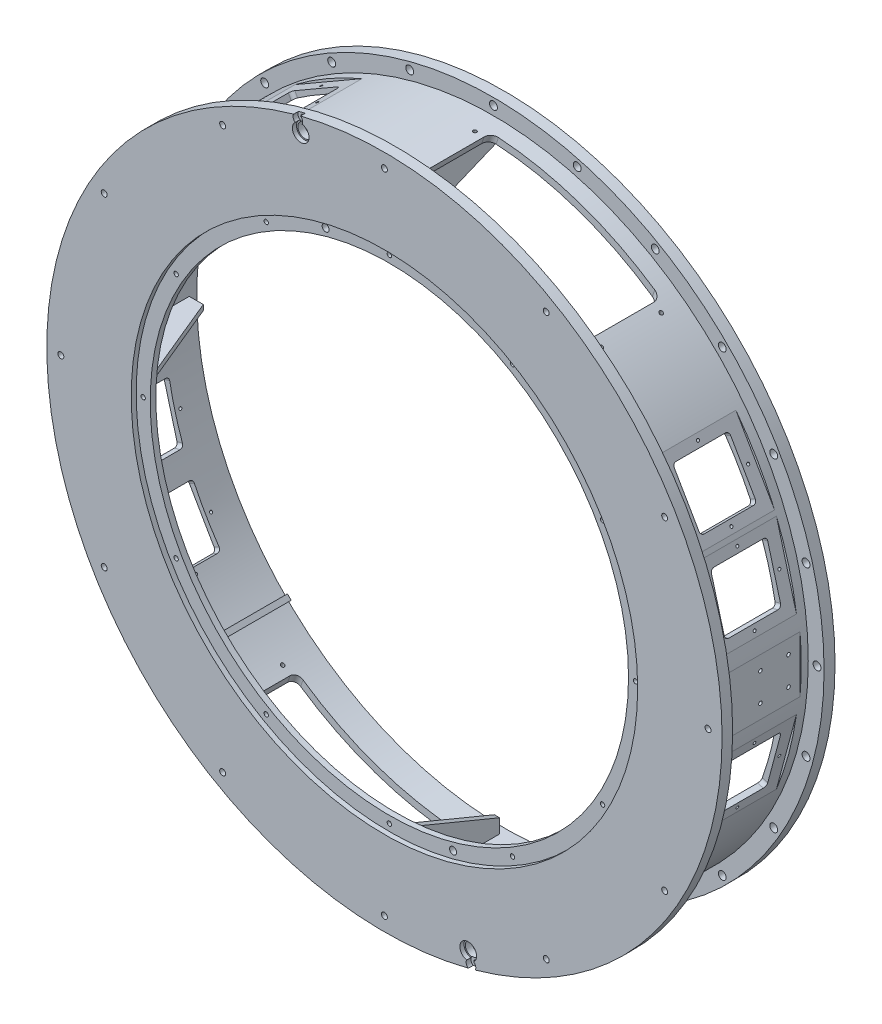
from build123d import *

# Parameters (mm, degrees)
F_1_2_13_TAPPED_HOLE1_REACH        = 218.662
F_1_2_13_TAPPED_HOLE1_BORE_R       = 5.35813
CIRPATTERN1_COUNT                  = 12
F_3_8_16_TAPPED_HOLE1_D            = 7.9375
CIRPATTERN2_COUNT                  = 12
F_9_16_0_5625_DIAMETER_HOLE1_D     = 14.2875
F_9_16_0_5625_DIAMETER_HOLE1_DEPTH = 19.813
CIRPATTERN3_COUNT                  = 24
HOLE1_D                            = 25.4
HOLE1_DEPTH                        = 19.051
HOLE1_CBORE_D                      = 30.1752
HOLE1_CBORE_DEPTH                  = 7.5184
F_5_16_18_TAPPED_HOLE1_D           = 6.5278
HOLE2_D                            = 17.4752
HOLE2_DEPTH                        = 8.6868
CIRPATTERN4_COUNT                  = 2
F_1_2_0_5_DIAMETER_HOLE1_D         = 12.7
CIRPATTERN5_COUNT                  = 2
EXTRUDE1_DEPTH                     = 4.7625
CIRPATTERN6_COUNT                  = 2
CIRPATTERN7_COUNT                  = 3
CIRPATTERN7_ANGLE                  = 90
CIRPATTERN7_COPY_1_DEPTH           = 4.7625
CIRPATTERN7_COPY_2_DEPTH           = 4.7625
EXTRUDE6_DEPTH                     = 4.7625
CIRPATTERN8_COUNT                  = 2
CUT_EXTRUDE1_DEPTH                 = 50.8
SKETCH23_R                         = 3.175
CUT_EXTRUDE3_DEPTH                 = 43.18
SKETCH27_W                         = 152.4
SKETCH27_H                         = 127
CUT_EXTRUDE4_DEPTH                 = 30.48
F_5_16_18_TAPPED_HOLE2_AT_2_COUNT  = 2
F_5_16_18_TAPPED_HOLE2_AT_2_PITCH  = 50.8
F_5_16_18_TAPPED_HOLE2_AT_3_COUNT  = 2
F_5_16_18_TAPPED_HOLE2_AT_3_PITCH  = 71.842048969
F_5_16_18_TAPPED_HOLE2_AT_4_COUNT  = 2
F_5_16_18_TAPPED_HOLE2_AT_4_PITCH  = 50.8
CIRPATTERN9_COUNT                  = 2
CIRPATTERN10_COUNT                 = 2
SKETCH31_W                         = 146.05
SKETCH31_H                         = 152.4
CUT_EXTRUDE6_DEPTH                 = 7.62
CUT_EXTRUDE7_DEPTH                 = 12.7
F_1_4_20_TAPPED_HOLE2_AT_2_COUNT   = 2
F_1_4_20_TAPPED_HOLE2_AT_2_PITCH   = 85.31243315
F_1_4_20_TAPPED_HOLE2_AT_3_COUNT   = 2
F_1_4_20_TAPPED_HOLE2_AT_3_PITCH   = 120.65
F_1_4_20_TAPPED_HOLE2_AT_4_COUNT   = 2
F_1_4_20_TAPPED_HOLE2_AT_4_PITCH   = 85.31243315
CIRPATTERN11_COUNT                 = 4
CIRPATTERN12_COUNT                 = 2
CIRPATTERN12_ANGLE                 = 15
CIRPATTERN13_COUNT                 = 2
CIRPATTERN13_ANGLE                 = 45
CIRPATTERN14_COUNT                 = 2
CIRPATTERN14_ANGLE                 = 165
CIRPATTERN15_COUNT                 = 2
CIRPATTERN15_ANGLE                 = 135


with BuildPart() as part:
    # Sketch1 → Revolve1 (revolve)
    with BuildSketch(Plane(origin=(0, 0, 0), x_dir=(0, 0, -1), z_dir=(1, 0, 0)), mode=Mode.PRIVATE) as revolve1_sk:
        Polygon((0, 609.6), (19.05, 609.6), (19.05, 568.325), (196.85, 568.325), (196.85, 596.9), (216.662, 596.9), (216.662, 555.625), (19.05, 555.625), (19.05, 431.8), (8.89, 431.8), (8.89, 457.2), (0, 457.2), align=None)
    revolve(revolve1_sk.sketch.rotate(Axis((0, 0, 0), (0, 0, -1)), 90), axis=Axis((0, 0, 0), (0, 0, -1)))  # turned: the seam where the file's is

    # 1_2-13 Tapped Hole1 bore (on position points) → 1_2-13 Tapped Hole1 (cut, up to next)
    with BuildSketch(Plane(origin=(0, 584.2, 0), x_dir=(1, 0, 0), z_dir=(0, 0, 1)), mode=Mode.PRIVATE) as f_1_2_13_tapped_hole1_sk1:
        Circle(F_1_2_13_TAPPED_HOLE1_BORE_R)
    f_1_2_13_tapped_hole1_tool1 = extrude(f_1_2_13_tapped_hole1_sk1.sketch, amount=-F_1_2_13_TAPPED_HOLE1_REACH, mode=Mode.PRIVATE) & part.part
    f_1_2_13_tapped_hole1 = f_1_2_13_tapped_hole1_tool1.solids().sort_by_distance((0, 584.2, 0))[0]
    add(f_1_2_13_tapped_hole1, mode=Mode.SUBTRACT)

    # CirPattern1: 1_2-13 Tapped Hole1 ×12 about axis
    cirpattern1_axis = Axis((0, 0, 0), (0, 0, 1))
    for i in range(1, CIRPATTERN1_COUNT):
        add(f_1_2_13_tapped_hole1.rotate(cirpattern1_axis, i * 360 / CIRPATTERN1_COUNT), mode=Mode.SUBTRACT)

    # 3_8-16 Tapped Hole1 (through all)
    with Locations(Plane(origin=(0, 444.5, -8.89), x_dir=(1, 0, 0), z_dir=(0, 0, 1))):
        with Locations((0, 0)):
            f_3_8_16_tapped_hole1 = Hole(F_3_8_16_TAPPED_HOLE1_D / 2)

    # CirPattern2: 3_8-16 Tapped Hole1 ×12 about axis
    cirpattern2_axis = Axis((0, 0, 0), (0, 0, 1))
    for i in range(1, CIRPATTERN2_COUNT):
        add(f_3_8_16_tapped_hole1.rotate(cirpattern2_axis, i * 360 / CIRPATTERN2_COUNT), mode=Mode.SUBTRACT)

    # 9_16 _0.5625_ Diameter Hole1
    with Locations(Plane(origin=(0, 584.2, -216.662), x_dir=(-1, 0, 0), z_dir=(0, 0, -1))):
        with Locations((0, 0)):
            f_9_16_0_5625_diameter_hole1 = Hole(F_9_16_0_5625_DIAMETER_HOLE1_D / 2, depth=F_9_16_0_5625_DIAMETER_HOLE1_DEPTH)

    # CirPattern3: 9_16 _0.5625_ Diameter Hole1 ×24 about axis
    cirpattern3_axis = Axis((0, 0, 0), (0, 0, 1))
    for i in range(1, CIRPATTERN3_COUNT):
        add(f_9_16_0_5625_diameter_hole1.rotate(cirpattern3_axis, i * 360 / CIRPATTERN3_COUNT), mode=Mode.SUBTRACT)

    # Hole1
    with Locations(Plane(origin=(-151.202086149, 564.293867718, 0), x_dir=(1, 0, 0), z_dir=(0, 0, 1))):
        with Locations((0, 0)):
            hole1 = CounterBoreHole(HOLE1_D / 2, HOLE1_CBORE_D / 2, HOLE1_CBORE_DEPTH, depth=HOLE1_DEPTH)

    # 5_16-18 Tapped Hole1 (through all)
    with Locations(Plane(origin=(-156.237773018, 583.087306965, 0), x_dir=(1, 0, 0), z_dir=(0, 0, 1))):
        with Locations((0, 0)):
            f_5_16_18_tapped_hole1 = Hole(F_5_16_18_TAPPED_HOLE1_D / 2)

    # Hole2
    with Locations(Plane(origin=(-156.237773018, 583.087306965, 0), x_dir=(1, 0, 0), z_dir=(0, 0, 1))):
        with Locations((0, 0)):
            hole2 = Hole(HOLE2_D / 2, depth=HOLE2_DEPTH)

    # CirPattern4: Hole1, 5_16-18 Tapped Hole1, Hole2 ×2 about axis
    cirpattern4_axis = Axis((0, 0, 0), (0, 0, 1))
    add([hole1.rotate(cirpattern4_axis, i * 360 / CIRPATTERN4_COUNT) for i in range(1, CIRPATTERN4_COUNT)], mode=Mode.SUBTRACT)
    add([f_5_16_18_tapped_hole1.rotate(cirpattern4_axis, i * 360 / CIRPATTERN4_COUNT) for i in range(1, CIRPATTERN4_COUNT)], mode=Mode.SUBTRACT)
    add([hole2.rotate(cirpattern4_axis, i * 360 / CIRPATTERN4_COUNT) for i in range(1, CIRPATTERN4_COUNT)], mode=Mode.SUBTRACT)

    # 1_2 _0.5_ Diameter Hole1 (through all)
    with Locations(Plane(origin=(-115.045065548, 429.354029785, -8.89), x_dir=(1, 0, 0), z_dir=(0, 0, 1))):
        with Locations((0, 0)):
            f_1_2_0_5_diameter_hole1 = Hole(F_1_2_0_5_DIAMETER_HOLE1_D / 2)

    # CirPattern5: 1_2 _0.5_ Diameter Hole1 ×2 about axis
    cirpattern5_axis = Axis((0, 0, 0), (0, 0, 1))
    for i in range(1, CIRPATTERN5_COUNT):
        add(f_1_2_0_5_diameter_hole1.rotate(cirpattern5_axis, i * 360 / CIRPATTERN5_COUNT), mode=Mode.SUBTRACT)

    # Sketch17 → Extrude1 (add, symmetric)
    with BuildSketch(Plane(origin=(0, 0, 0), x_dir=(0, 0, -1), z_dir=(1, 0, 0))):
        Polygon((203.2, 555.625), (203.2, 530.225), (19.05, 454.025), (19.05, 546.644743879), (28.030256121, 555.625), align=None)
    extrude1 = extrude(amount=EXTRUDE1_DEPTH, both=True)

    # CirPattern6: Extrude1 ×2 about axis
    cirpattern6_axis = Axis((0, 0, 0), (0, 0, 1))
    for i in range(1, CIRPATTERN6_COUNT):
        add(extrude1.rotate(cirpattern6_axis, i * 360 / CIRPATTERN6_COUNT))

    # CirPattern7: Extrude1 ×3 about axis
    cirpattern7_axis = Axis((0, 0, 0), (0, 0, 1))
    for i in range(1, CIRPATTERN7_COUNT):
        add(extrude1.rotate(cirpattern7_axis, i * CIRPATTERN7_ANGLE / (CIRPATTERN7_COUNT - 1)))

    # CirPattern7 copy 1 sketch → CirPattern7 copy 1 (add, symmetric)
    with BuildSketch(Plane(origin=(0, 0, 0), x_dir=(0, 0, -1), z_dir=(-0.707106781, -0.707106781, 0))):
        Polygon((203.2, 555.625), (203.2, 530.225), (19.05, 454.025), (19.05, 546.644743879), (28.030256121, 555.625), align=None)
    extrude(amount=CIRPATTERN7_COPY_1_DEPTH, both=True)

    # CirPattern7 copy 2 sketch → CirPattern7 copy 2 (add, symmetric)
    with BuildSketch(Plane(origin=(0, 0, 0), x_dir=(0, 0, -1), z_dir=(0, -1, 0))):
        Polygon((203.2, 555.625), (203.2, 530.225), (19.05, 454.025), (19.05, 546.644743879), (28.030256121, 555.625), align=None)
    extrude(amount=CIRPATTERN7_COPY_2_DEPTH, both=True)

    # Sketch20 → Extrude6 (add, symmetric)
    with BuildSketch(Plane(origin=(0, 0, 0), x_dir=(0.707106781, 0.707106781, 0), z_dir=(0.707106781, -0.707106781, 0))):
        Polygon((504.825, -19.05), (546.644743879, -19.05), (555.625, -28.030256121), (555.625, -203.2), (530.225, -203.2), align=None)
    extrude6 = extrude(amount=EXTRUDE6_DEPTH, both=True)

    # CirPattern8: Extrude6 ×2 about axis
    cirpattern8_axis = Axis((0, 0, 0), (0, 0, 1))
    for i in range(1, CIRPATTERN8_COUNT):
        add(extrude6.rotate(cirpattern8_axis, i * 360 / CIRPATTERN8_COUNT))

    # Sketch22 → Cut-Extrude1 (cut)
    with BuildSketch(Plane(origin=(185.028521382, 537.361844477, 0), x_dir=(0.945518576, -0.325568154, 0), z_dir=(-0.325568154, -0.945518576, 0))):
        with BuildLine():
            ThreePointArc((-161.925, -41.402), (-158.205256121, -32.421743879), (-149.225, -28.702))
            Line((-149.225, -28.702), (149.225, -28.702))
            ThreePointArc((149.225, -28.702), (158.205256121, -32.421743879), (161.925, -41.402))
            Line((161.925, -41.402), (161.925, -155.702))
            ThreePointArc((161.925, -155.702), (158.205256121, -164.682256121), (149.225, -168.402))
            Line((149.225, -168.402), (-149.225, -168.402))
            ThreePointArc((-149.225, -168.402), (-158.205256121, -164.682256121), (-161.925, -155.702))
            Line((-161.925, -155.702), (-161.925, -41.402))
        make_face()
    cut_extrude1 = extrude(amount=CUT_EXTRUDE1_DEPTH, mode=Mode.SUBTRACT)

    # Sketch23 → Cut-Extrude3 (cut)
    with BuildSketch(Plane(origin=(185.028521382, 537.361844477, 0), x_dir=(0.945518576, -0.325568154, 0), z_dir=(-0.325568154, -0.945518576, 0))):
        with Locations(Location((-177.8, -47.752, 0), (0, 0, 180))):  # turned: the seam where the file's is
            Circle(SKETCH23_R)
        with Locations(Location((-177.8, -155.702, 0), (0, 0, 180))):  # turned: the seam where the file's is
            Circle(SKETCH23_R)
        with Locations(Location((177.8, -47.752, 0), (0, 0, 180))):  # turned: the seam where the file's is
            Circle(SKETCH23_R)
        with Locations(Location((177.8, -155.702, 0), (0, 0, 180))):  # turned: the seam where the file's is
            Circle(SKETCH23_R)
    cut_extrude3 = extrude(amount=CUT_EXTRUDE3_DEPTH, mode=Mode.SUBTRACT)

    # Sketch27 → Cut-Extrude4 (cut)
    with BuildSketch(Plane(origin=(566.050055759, 0, 0), x_dir=(0, 0, -1), z_dir=(1, 0, 0))):
        with Locations((107.95, 0)):
            Rectangle(SKETCH27_W, SKETCH27_H)
    cut_extrude4 = extrude(amount=CUT_EXTRUDE4_DEPTH, mode=Mode.SUBTRACT)

    # Sketch29 → 5_16-18 Tapped Hole2 (revolve, cut)
    with BuildSketch(Plane(origin=(566.050055759, 25.4, -112.7125), x_dir=(0, 0, -1), z_dir=(0, 1, 0))):
        Polygon((0, 0), (0, 32.695148974), (3.2639, 30.734), (3.2639, 0), align=None)
    f_5_16_18_tapped_hole2 = revolve(axis=Axis((572.400055759, 25.4, -112.7125), (-1, 0, 0)), mode=Mode.SUBTRACT)

    # 5_16-18 Tapped Hole2 at 2: 5_16-18 Tapped Hole2 ×2
    with Locations(*[(0, 0, -i * F_5_16_18_TAPPED_HOLE2_AT_2_PITCH) for i in range(1, F_5_16_18_TAPPED_HOLE2_AT_2_COUNT)]):
        add(f_5_16_18_tapped_hole2, mode=Mode.SUBTRACT)

    # 5_16-18 Tapped Hole2 at 3: 5_16-18 Tapped Hole2 ×2
    with Locations(*[Vector(0, -0.707106781, -0.707106781) * (i * F_5_16_18_TAPPED_HOLE2_AT_3_PITCH) for i in range(1, F_5_16_18_TAPPED_HOLE2_AT_3_COUNT)]):
        add(f_5_16_18_tapped_hole2, mode=Mode.SUBTRACT)

    # 5_16-18 Tapped Hole2 at 4: 5_16-18 Tapped Hole2 ×2
    with Locations(*[(0, -i * F_5_16_18_TAPPED_HOLE2_AT_4_PITCH, 0) for i in range(1, F_5_16_18_TAPPED_HOLE2_AT_4_COUNT)]):
        add(f_5_16_18_tapped_hole2, mode=Mode.SUBTRACT)

    # CirPattern9: 5_16-18 Tapped Hole2, Cut-Extrude4 ×2 about axis
    cirpattern9_axis = Axis((0, 0, 0), (0, 0, -1))
    add([f_5_16_18_tapped_hole2.rotate(cirpattern9_axis, i * 360 / CIRPATTERN9_COUNT) for i in range(1, CIRPATTERN9_COUNT)], mode=Mode.SUBTRACT)
    add([cut_extrude4.rotate(cirpattern9_axis, i * 360 / CIRPATTERN9_COUNT) for i in range(1, CIRPATTERN9_COUNT)], mode=Mode.SUBTRACT)

    # CirPattern9 copy 1 sketch → CirPattern9 copy 1 (revolve, cut)
    with BuildSketch(Plane(origin=(-566.050055759, -25.4, -163.5125), x_dir=(0, 0, -1), z_dir=(0, -1, 0))):
        Polygon((0, 0), (0, 32.695148974), (3.2639, 30.734), (3.2639, 0), align=None)
    revolve(axis=Axis((-572.400055759, -25.4, -163.5125), (1, 0, 0)), mode=Mode.SUBTRACT)

    # CirPattern9 copy 2 sketch → CirPattern9 copy 2 (revolve, cut)
    with BuildSketch(Plane(origin=(-566.050055759, 25.4, -163.5125), x_dir=(0, 0, -1), z_dir=(0, -1, 0))):
        Polygon((0, 0), (0, 32.695148974), (3.2639, 30.734), (3.2639, 0), align=None)
    revolve(axis=Axis((-572.400055759, 25.4, -163.5125), (1, 0, 0)), mode=Mode.SUBTRACT)

    # CirPattern9 copy 3 sketch → CirPattern9 copy 3 (revolve, cut)
    with BuildSketch(Plane(origin=(-566.050055759, 25.4, -112.7125), x_dir=(0, 0, -1), z_dir=(0, -1, 0))):
        Polygon((0, 0), (0, 32.695148974), (3.2639, 30.734), (3.2639, 0), align=None)
    revolve(axis=Axis((-572.400055759, 25.4, -112.7125), (1, 0, 0)), mode=Mode.SUBTRACT)

    # CirPattern10: Cut-Extrude1, Cut-Extrude3 ×2 about axis
    cirpattern10_axis = Axis((0, 0, 0), (0, 0, 1))
    add([cut_extrude1.rotate(cirpattern10_axis, i * 360 / CIRPATTERN10_COUNT) for i in range(1, CIRPATTERN10_COUNT)], mode=Mode.SUBTRACT)
    add([cut_extrude3.rotate(cirpattern10_axis, i * 360 / CIRPATTERN10_COUNT) for i in range(1, CIRPATTERN10_COUNT)], mode=Mode.SUBTRACT)

    # Sketch31 → Cut-Extrude6 (cut)
    with BuildSketch(Plane(origin=(488.452364457, 282.008104106, 0), x_dir=(0, 0, 1), z_dir=(-0.866025404, -0.5, 0))):
        with Locations((-107.95, 0)):
            Rectangle(SKETCH31_W, SKETCH31_H)
    cut_extrude6 = extrude(amount=-CUT_EXTRUDE6_DEPTH, mode=Mode.SUBTRACT)

    # Sketch32 → Cut-Extrude7 (cut)
    with BuildSketch(Plane(origin=(488.452364457, 282.008104106, 0), x_dir=(0, 0, -1), z_dir=(0.866025404, 0.5, 0))):
        with BuildLine():
            Line((63.5, 50.8), (152.4, 50.8))
            ThreePointArc((152.4, 50.8), (156.890128061, 48.940128061), (158.75, 44.45))
            Line((158.75, 44.45), (158.75, -44.45))
            ThreePointArc((158.75, -44.45), (156.890128061, -48.940128061), (152.4, -50.8))
            Line((152.4, -50.8), (63.5, -50.8))
            ThreePointArc((63.5, -50.8), (59.009871939, -48.940128061), (57.15, -44.45))
            Line((57.15, -44.45), (57.15, 44.45))
            ThreePointArc((57.15, 44.45), (59.009871939, 48.940128061), (63.5, 50.8))
        make_face()
    cut_extrude7 = extrude(amount=-CUT_EXTRUDE7_DEPTH, mode=Mode.SUBTRACT)

    # Sketch34 → 1_4-20 Tapped Hole2 (revolve, cut)
    with BuildSketch(Plane(origin=(458.289864457, 334.251086589, -107.95), x_dir=(-0.5, 0.866025404, 0), z_dir=(0, 0, 1))):
        Polygon((0, 0), (0, 25.663816902), (2.5527, 24.13), (2.5527, 0), align=None)
    f_1_4_20_tapped_hole2 = revolve(axis=Axis((463.789125771, 337.426086589, -107.95), (-0.866025404, -0.5, 0)), mode=Mode.SUBTRACT)

    # 1_4-20 Tapped Hole2 at 2: 1_4-20 Tapped Hole2 ×2
    with Locations(*[Vector(0.353553391, -0.612372436, -0.707106781) * (i * F_1_4_20_TAPPED_HOLE2_AT_2_PITCH) for i in range(1, F_1_4_20_TAPPED_HOLE2_AT_2_COUNT)]):
        add(f_1_4_20_tapped_hole2, mode=Mode.SUBTRACT)

    # 1_4-20 Tapped Hole2 at 3: 1_4-20 Tapped Hole2 ×2
    with Locations(*[Vector(0.5, -0.866025404, 0) * (i * F_1_4_20_TAPPED_HOLE2_AT_3_PITCH) for i in range(1, F_1_4_20_TAPPED_HOLE2_AT_3_COUNT)]):
        add(f_1_4_20_tapped_hole2, mode=Mode.SUBTRACT)

    # 1_4-20 Tapped Hole2 at 4: 1_4-20 Tapped Hole2 ×2
    with Locations(*[Vector(0.353553391, -0.612372436, 0.707106781) * (i * F_1_4_20_TAPPED_HOLE2_AT_4_PITCH) for i in range(1, F_1_4_20_TAPPED_HOLE2_AT_4_COUNT)]):
        add(f_1_4_20_tapped_hole2, mode=Mode.SUBTRACT)

    # CirPattern11: 1_4-20 Tapped Hole2, Cut-Extrude7, Cut-Extrude6 ×4 about axis
    cirpattern11_axis = Axis((0, 0, 0), (0, 0, 1))
    add([f_1_4_20_tapped_hole2.rotate(cirpattern11_axis, i * 360 / CIRPATTERN11_COUNT) for i in range(1, CIRPATTERN11_COUNT)], mode=Mode.SUBTRACT)
    add([cut_extrude7.rotate(cirpattern11_axis, i * 360 / CIRPATTERN11_COUNT) for i in range(1, CIRPATTERN11_COUNT)], mode=Mode.SUBTRACT)
    add([cut_extrude6.rotate(cirpattern11_axis, i * 360 / CIRPATTERN11_COUNT) for i in range(1, CIRPATTERN11_COUNT)], mode=Mode.SUBTRACT)

    # CirPattern11 copy 1 sketch → CirPattern11 copy 1 (revolve, cut)
    with BuildSketch(Plane(origin=(-282.008104106, 488.452364457, -168.275), x_dir=(-0.866025404, -0.5, 0), z_dir=(0, 0, 1))):
        Polygon((0, 0), (0, 25.663816902), (2.5527, 24.13), (2.5527, 0), align=None)
    revolve(axis=Axis((-285.183104106, 493.951625771, -168.275), (0.5, -0.866025404, 0)), mode=Mode.SUBTRACT)

    # CirPattern11 copy 2 sketch → CirPattern11 copy 2 (revolve, cut)
    with BuildSketch(Plane(origin=(-488.452364457, -282.008104106, -168.275), x_dir=(0.5, -0.866025404, 0), z_dir=(0, 0, 1))):
        Polygon((0, 0), (0, 25.663816902), (2.5527, 24.13), (2.5527, 0), align=None)
    revolve(axis=Axis((-493.951625771, -285.183104106, -168.275), (0.866025404, 0.5, 0)), mode=Mode.SUBTRACT)

    # CirPattern11 copy 3 sketch → CirPattern11 copy 3 (revolve, cut)
    with BuildSketch(Plane(origin=(282.008104106, -488.452364457, -168.275), x_dir=(0.866025404, 0.5, 0), z_dir=(0, 0, 1))):
        Polygon((0, 0), (0, 25.663816902), (2.5527, 24.13), (2.5527, 0), align=None)
    revolve(axis=Axis((285.183104106, -493.951625771, -168.275), (-0.5, 0.866025404, 0)), mode=Mode.SUBTRACT)

    # CirPattern11 copy 4 sketch → CirPattern11 copy 4 (revolve, cut)
    with BuildSketch(Plane(origin=(-229.765121622, 518.614864457, -107.95), x_dir=(-0.866025404, -0.5, 0), z_dir=(0, 0, 1))):
        Polygon((0, 0), (0, 25.663816902), (2.5527, 24.13), (2.5527, 0), align=None)
    revolve(axis=Axis((-232.940121622, 524.114125771, -107.95), (0.5, -0.866025404, 0)), mode=Mode.SUBTRACT)

    # CirPattern11 copy 5 sketch → CirPattern11 copy 5 (revolve, cut)
    with BuildSketch(Plane(origin=(-518.614864457, -229.765121622, -107.95), x_dir=(0.5, -0.866025404, 0), z_dir=(0, 0, 1))):
        Polygon((0, 0), (0, 25.663816902), (2.5527, 24.13), (2.5527, 0), align=None)
    revolve(axis=Axis((-524.114125771, -232.940121622, -107.95), (0.866025404, 0.5, 0)), mode=Mode.SUBTRACT)

    # CirPattern11 copy 6 sketch → CirPattern11 copy 6 (revolve, cut)
    with BuildSketch(Plane(origin=(229.765121622, -518.614864457, -107.95), x_dir=(0.866025404, 0.5, 0), z_dir=(0, 0, 1))):
        Polygon((0, 0), (0, 25.663816902), (2.5527, 24.13), (2.5527, 0), align=None)
    revolve(axis=Axis((232.940121622, -524.114125771, -107.95), (-0.5, 0.866025404, 0)), mode=Mode.SUBTRACT)

    # CirPattern11 copy 7 sketch → CirPattern11 copy 7 (revolve, cut)
    with BuildSketch(Plane(origin=(-282.008104106, 488.452364457, -47.625), x_dir=(-0.866025404, -0.5, 0), z_dir=(0, 0, 1))):
        Polygon((0, 0), (0, 25.663816902), (2.5527, 24.13), (2.5527, 0), align=None)
    revolve(axis=Axis((-285.183104106, 493.951625771, -47.625), (0.5, -0.866025404, 0)), mode=Mode.SUBTRACT)

    # CirPattern11 copy 8 sketch → CirPattern11 copy 8 (revolve, cut)
    with BuildSketch(Plane(origin=(-488.452364457, -282.008104106, -47.625), x_dir=(0.5, -0.866025404, 0), z_dir=(0, 0, 1))):
        Polygon((0, 0), (0, 25.663816902), (2.5527, 24.13), (2.5527, 0), align=None)
    revolve(axis=Axis((-493.951625771, -285.183104106, -47.625), (0.866025404, 0.5, 0)), mode=Mode.SUBTRACT)

    # CirPattern11 copy 9 sketch → CirPattern11 copy 9 (revolve, cut)
    with BuildSketch(Plane(origin=(282.008104106, -488.452364457, -47.625), x_dir=(0.866025404, 0.5, 0), z_dir=(0, 0, 1))):
        Polygon((0, 0), (0, 25.663816902), (2.5527, 24.13), (2.5527, 0), align=None)
    revolve(axis=Axis((285.183104106, -493.951625771, -47.625), (-0.5, 0.866025404, 0)), mode=Mode.SUBTRACT)

    # CirPattern12: Cut-Extrude7, Cut-Extrude6, 1_4-20 Tapped Hole2 ×2 about axis
    cirpattern12_axis = Axis((0, 0, 0), (0, 0, -1))
    add([cut_extrude7.rotate(cirpattern12_axis, i * CIRPATTERN12_ANGLE / (CIRPATTERN12_COUNT - 1)) for i in range(1, CIRPATTERN12_COUNT)], mode=Mode.SUBTRACT)
    add([cut_extrude6.rotate(cirpattern12_axis, i * CIRPATTERN12_ANGLE / (CIRPATTERN12_COUNT - 1)) for i in range(1, CIRPATTERN12_COUNT)], mode=Mode.SUBTRACT)
    add([f_1_4_20_tapped_hole2.rotate(cirpattern12_axis, i * CIRPATTERN12_ANGLE / (CIRPATTERN12_COUNT - 1)) for i in range(1, CIRPATTERN12_COUNT)], mode=Mode.SUBTRACT)

    # CirPattern12 copy 1 sketch → CirPattern12 copy 1 (revolve, cut)
    with BuildSketch(Plane(origin=(544.797821957, 145.978136432, -168.275), x_dir=(-0.258819045, 0.965925826, 0), z_dir=(0, 0, 1))):
        Polygon((0, 0), (0, 25.663816902), (2.5527, 24.13), (2.5527, 0), align=None)
    revolve(axis=Axis((550.931450954, 147.621637368, -168.275), (-0.965925826, -0.258819045, 0)), mode=Mode.SUBTRACT)

    # CirPattern12 copy 2 sketch → CirPattern12 copy 2 (revolve, cut)
    with BuildSketch(Plane(origin=(560.411080853, 87.708660961, -107.95), x_dir=(-0.258819045, 0.965925826, 0), z_dir=(0, 0, 1))):
        Polygon((0, 0), (0, 25.663816902), (2.5527, 24.13), (2.5527, 0), align=None)
    revolve(axis=Axis((566.54470985, 89.352161897, -107.95), (-0.965925826, -0.258819045, 0)), mode=Mode.SUBTRACT)

    # CirPattern12 copy 3 sketch → CirPattern12 copy 3 (revolve, cut)
    with BuildSketch(Plane(origin=(544.797821957, 145.978136432, -47.625), x_dir=(-0.258819045, 0.965925826, 0), z_dir=(0, 0, 1))):
        Polygon((0, 0), (0, 25.663816902), (2.5527, 24.13), (2.5527, 0), align=None)
    revolve(axis=Axis((550.931450954, 147.621637368, -47.625), (-0.965925826, -0.258819045, 0)), mode=Mode.SUBTRACT)

    # CirPattern13: 1_4-20 Tapped Hole2, Cut-Extrude7, Cut-Extrude6 ×2 about axis
    cirpattern13_axis = Axis((0, 0, 0), (0, 0, -1))
    add([f_1_4_20_tapped_hole2.rotate(cirpattern13_axis, i * CIRPATTERN13_ANGLE / (CIRPATTERN13_COUNT - 1)) for i in range(1, CIRPATTERN13_COUNT)], mode=Mode.SUBTRACT)
    add([cut_extrude7.rotate(cirpattern13_axis, i * CIRPATTERN13_ANGLE / (CIRPATTERN13_COUNT - 1)) for i in range(1, CIRPATTERN13_COUNT)], mode=Mode.SUBTRACT)
    add([cut_extrude6.rotate(cirpattern13_axis, i * CIRPATTERN13_ANGLE / (CIRPATTERN13_COUNT - 1)) for i in range(1, CIRPATTERN13_COUNT)], mode=Mode.SUBTRACT)

    # CirPattern13 copy 1 sketch → CirPattern13 copy 1 (revolve, cut)
    with BuildSketch(Plane(origin=(544.797821957, -145.978136432, -168.275), x_dir=(0.258819045, 0.965925826, 0), z_dir=(0, 0, 1))):
        Polygon((0, 0), (0, 25.663816902), (2.5527, 24.13), (2.5527, 0), align=None)
    revolve(axis=Axis((550.931450954, -147.621637368, -168.275), (-0.965925826, 0.258819045, 0)), mode=Mode.SUBTRACT)

    # CirPattern13 copy 2 sketch → CirPattern13 copy 2 (revolve, cut)
    with BuildSketch(Plane(origin=(529.184563061, -204.247611902, -107.95), x_dir=(0.258819045, 0.965925826, 0), z_dir=(0, 0, 1))):
        Polygon((0, 0), (0, 25.663816902), (2.5527, 24.13), (2.5527, 0), align=None)
    revolve(axis=Axis((535.318192058, -205.891112839, -107.95), (-0.965925826, 0.258819045, 0)), mode=Mode.SUBTRACT)

    # CirPattern13 copy 3 sketch → CirPattern13 copy 3 (revolve, cut)
    with BuildSketch(Plane(origin=(544.797821957, -145.978136432, -47.625), x_dir=(0.258819045, 0.965925826, 0), z_dir=(0, 0, 1))):
        Polygon((0, 0), (0, 25.663816902), (2.5527, 24.13), (2.5527, 0), align=None)
    revolve(axis=Axis((550.931450954, -147.621637368, -47.625), (-0.965925826, 0.258819045, 0)), mode=Mode.SUBTRACT)

    # CirPattern14: 1_4-20 Tapped Hole2, Cut-Extrude7, Cut-Extrude6 ×2 about axis
    cirpattern14_axis = Axis((0, 0, 0), (0, 0, 1))
    add([f_1_4_20_tapped_hole2.rotate(cirpattern14_axis, i * CIRPATTERN14_ANGLE / (CIRPATTERN14_COUNT - 1)) for i in range(1, CIRPATTERN14_COUNT)], mode=Mode.SUBTRACT)
    add([cut_extrude7.rotate(cirpattern14_axis, i * CIRPATTERN14_ANGLE / (CIRPATTERN14_COUNT - 1)) for i in range(1, CIRPATTERN14_COUNT)], mode=Mode.SUBTRACT)
    add([cut_extrude6.rotate(cirpattern14_axis, i * CIRPATTERN14_ANGLE / (CIRPATTERN14_COUNT - 1)) for i in range(1, CIRPATTERN14_COUNT)], mode=Mode.SUBTRACT)

    # CirPattern14 copy 1 sketch → CirPattern14 copy 1 (revolve, cut)
    with BuildSketch(Plane(origin=(-544.797821957, -145.978136432, -168.275), x_dir=(0.258819045, -0.965925826, 0), z_dir=(0, 0, 1))):
        Polygon((0, 0), (0, 25.663816902), (2.5527, 24.13), (2.5527, 0), align=None)
    revolve(axis=Axis((-550.931450954, -147.621637368, -168.275), (0.965925826, 0.258819045, 0)), mode=Mode.SUBTRACT)

    # CirPattern14 copy 2 sketch → CirPattern14 copy 2 (revolve, cut)
    with BuildSketch(Plane(origin=(-560.411080853, -87.708660961, -107.95), x_dir=(0.258819045, -0.965925826, 0), z_dir=(0, 0, 1))):
        Polygon((0, 0), (0, 25.663816902), (2.5527, 24.13), (2.5527, 0), align=None)
    revolve(axis=Axis((-566.54470985, -89.352161897, -107.95), (0.965925826, 0.258819045, 0)), mode=Mode.SUBTRACT)

    # CirPattern14 copy 3 sketch → CirPattern14 copy 3 (revolve, cut)
    with BuildSketch(Plane(origin=(-544.797821957, -145.978136432, -47.625), x_dir=(0.258819045, -0.965925826, 0), z_dir=(0, 0, 1))):
        Polygon((0, 0), (0, 25.663816902), (2.5527, 24.13), (2.5527, 0), align=None)
    revolve(axis=Axis((-550.931450954, -147.621637368, -47.625), (0.965925826, 0.258819045, 0)), mode=Mode.SUBTRACT)

    # CirPattern15: 1_4-20 Tapped Hole2, Cut-Extrude7, Cut-Extrude6 ×2 about axis
    cirpattern15_axis = Axis((0, 0, 0), (0, 0, 1))
    add([f_1_4_20_tapped_hole2.rotate(cirpattern15_axis, i * CIRPATTERN15_ANGLE / (CIRPATTERN15_COUNT - 1)) for i in range(1, CIRPATTERN15_COUNT)], mode=Mode.SUBTRACT)
    add([cut_extrude7.rotate(cirpattern15_axis, i * CIRPATTERN15_ANGLE / (CIRPATTERN15_COUNT - 1)) for i in range(1, CIRPATTERN15_COUNT)], mode=Mode.SUBTRACT)
    add([cut_extrude6.rotate(cirpattern15_axis, i * CIRPATTERN15_ANGLE / (CIRPATTERN15_COUNT - 1)) for i in range(1, CIRPATTERN15_COUNT)], mode=Mode.SUBTRACT)

    # CirPattern15 copy 1 sketch → CirPattern15 copy 1 (revolve, cut)
    with BuildSketch(Plane(origin=(-544.797821957, 145.978136432, -168.275), x_dir=(-0.258819045, -0.965925826, 0), z_dir=(0, 0, 1))):
        Polygon((0, 0), (0, 25.663816902), (2.5527, 24.13), (2.5527, 0), align=None)
    revolve(axis=Axis((-550.931450954, 147.621637368, -168.275), (0.965925826, -0.258819045, 0)), mode=Mode.SUBTRACT)

    # CirPattern15 copy 2 sketch → CirPattern15 copy 2 (revolve, cut)
    with BuildSketch(Plane(origin=(-529.184563061, 204.247611902, -107.95), x_dir=(-0.258819045, -0.965925826, 0), z_dir=(0, 0, 1))):
        Polygon((0, 0), (0, 25.663816902), (2.5527, 24.13), (2.5527, 0), align=None)
    revolve(axis=Axis((-535.318192058, 205.891112839, -107.95), (0.965925826, -0.258819045, 0)), mode=Mode.SUBTRACT)

    # CirPattern15 copy 3 sketch → CirPattern15 copy 3 (revolve, cut)
    with BuildSketch(Plane(origin=(-544.797821957, 145.978136432, -47.625), x_dir=(-0.258819045, -0.965925826, 0), z_dir=(0, 0, 1))):
        Polygon((0, 0), (0, 25.663816902), (2.5527, 24.13), (2.5527, 0), align=None)
    revolve(axis=Axis((-550.931450954, 147.621637368, -47.625), (0.965925826, -0.258819045, 0)), mode=Mode.SUBTRACT)


solid = part.part
